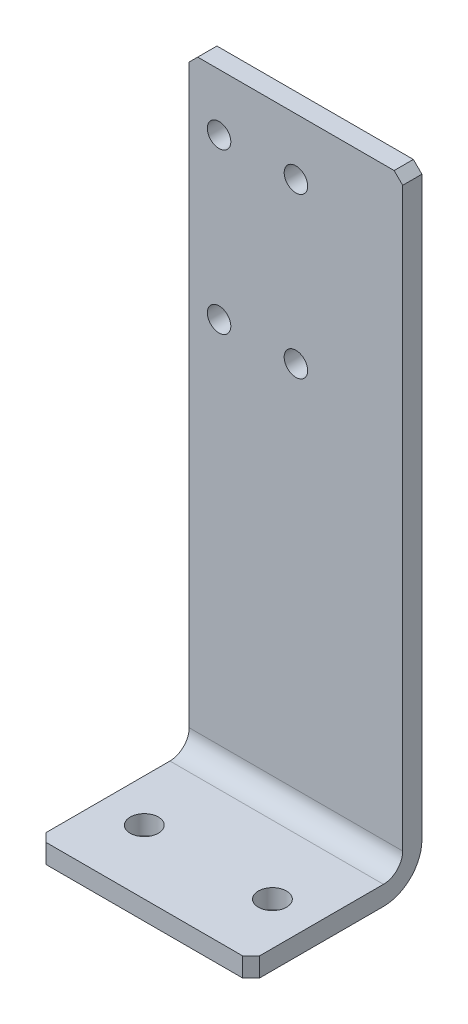
from build123d import *

# Parameters (mm, degrees)
BOSS_EXTRUDE1_DEPTH  = 25
FILLET1_R            = 4.5
FILLET2_R            = 9
M6_CLEARANCE_HOLE1_D = 6.6
M5_CLEARANCE_HOLE1_D = 5.5
CHAMFER1_SIZE        = 2


with BuildPart() as part:
    # Sketch1 → Boss-Extrude1 (new body, symmetric)
    with BuildSketch(Plane(origin=(0, 0, 0), x_dir=(0, 0, -1), z_dir=(1, 0, 0))):
        Polygon((0, 0), (-40, 0), (-40, 4.5), (-4.5, 4.5), (-4.5, 146), (0, 146), align=None)
    extrude(amount=BOSS_EXTRUDE1_DEPTH, both=True)

    # Fillet1
    fillet1_edges = [part.edges().sort_by_distance(p)[0] for p in [
        (0, 4.5, 4.5),
    ]]
    fillet(fillet1_edges, radius=FILLET1_R)

    # Fillet2
    fillet2_edges = [part.edges().sort_by_distance(p)[0] for p in [
        (0, 0, 0),
    ]]
    fillet(fillet2_edges, radius=FILLET2_R)

    # M6 Clearance Hole1 (through all)
    with Locations(Plane(origin=(0, 4.5, 0), x_dir=(-1, 0, 0), z_dir=(0, 1, 0))):
        with Locations((15, 25), (-15, 25)):
            Hole(M6_CLEARANCE_HOLE1_D / 2)

    # M5 Clearance Hole1 (through all)
    with Locations(Plane(origin=(0, 0, 0), x_dir=(-1, 0, 0), z_dir=(0, 0, -1))):
        with Locations((18, 132.7), (0, 132.7), (0, 95.3), (18, 95.3)):
            Hole(M5_CLEARANCE_HOLE1_D / 2)

    # Chamfer1
    chamfer1_edges = [part.edges().sort_by_distance(p)[0] for p in [
        (25, 2.25, 40),
        (25, 146, 2.25),
        (-25, 146, 2.25),
        (-25, 2.25, 40),
    ]]
    chamfer(chamfer1_edges, length=CHAMFER1_SIZE)


solid = part.part
